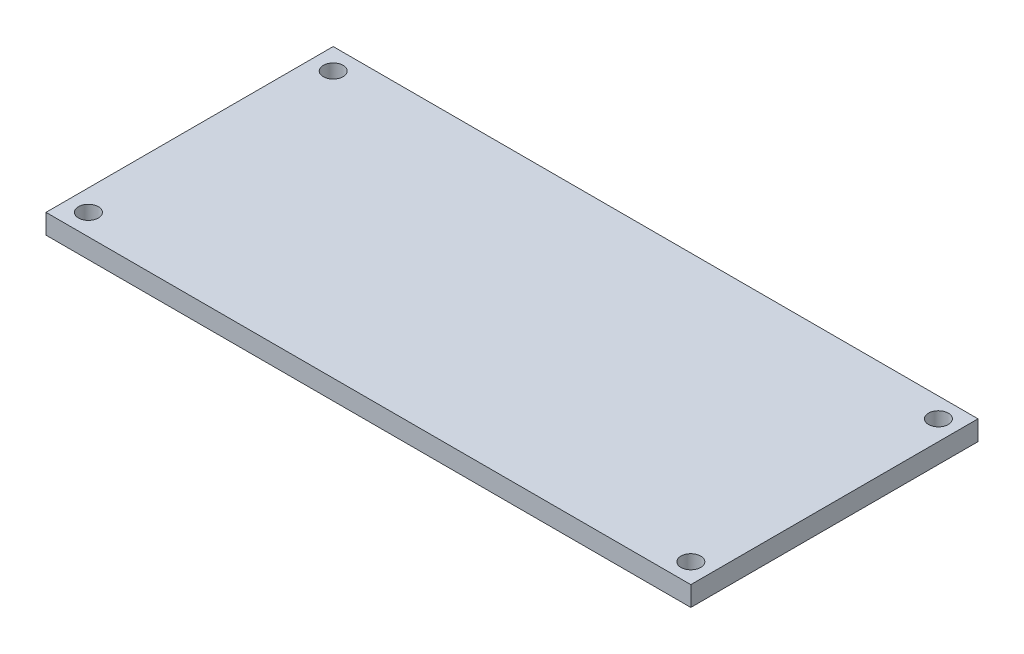
from build123d import *

# Parameters (mm, degrees)
SKETCH1_W           = 45.6
SKETCH1_H           = 20.31
SKETCH1_R           = 0.7
BOSS_EXTRUDE1_DEPTH = 1.4


with BuildPart() as part:
    # Sketch1 → Boss-Extrude1 (new body)
    with BuildSketch(Plane(origin=(0, 0, 0), x_dir=(1, 0, 0), z_dir=(0, 1, 0))):
        with Locations((0.139240669, 2.007420382)):
            Rectangle(SKETCH1_W, SKETCH1_H)
        with Locations((-21.160759331, 10.662420382)):
            Circle(SKETCH1_R, mode=Mode.SUBTRACT)
        with Locations((-21.160759331, -6.647579618)):
            Circle(SKETCH1_R, mode=Mode.SUBTRACT)
        with Locations((21.539240669, 10.762420382)):
            Circle(SKETCH1_R, mode=Mode.SUBTRACT)
        with Locations((21.539240669, -6.747579618)):
            Circle(SKETCH1_R, mode=Mode.SUBTRACT)
    extrude(amount=BOSS_EXTRUDE1_DEPTH)


solid = part.part
